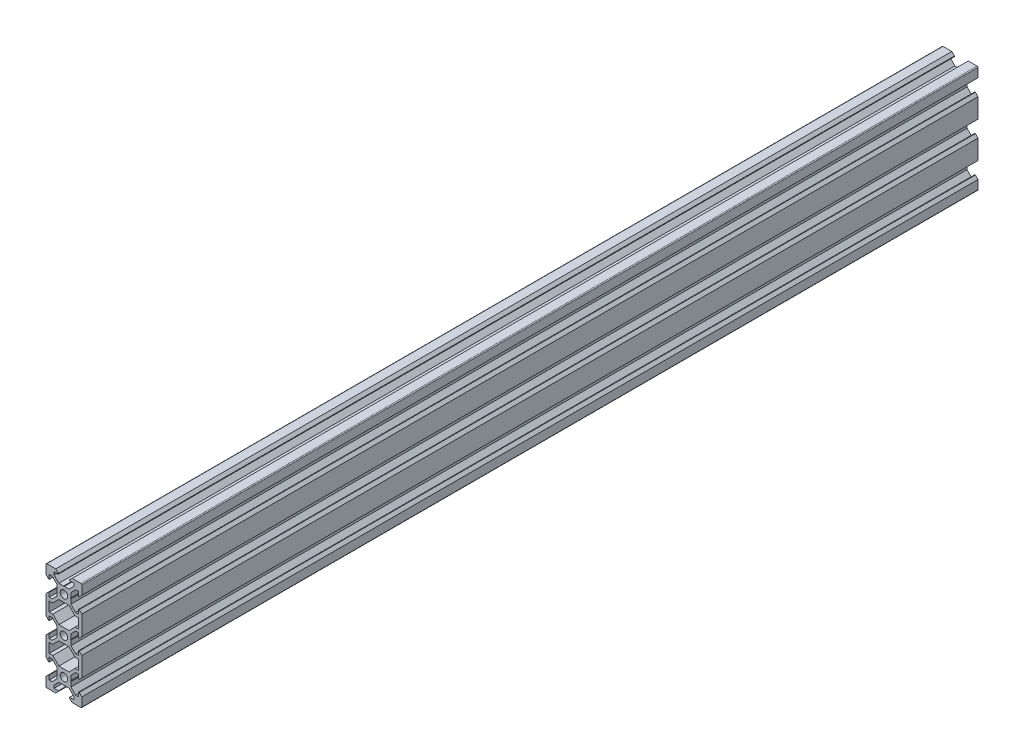
from build123d import *

# Parameters (mm, degrees)
SKETCH1_R           = 2.1
BOSS_EXTRUDE1_DEPTH = 500


with BuildPart() as part:
    # Sketch1 → Boss-Extrude1 (new body)
    with BuildSketch(Plane.XY):
        with BuildLine():
            Line((4.58, -30), (9.5, -30))
            ThreePointArc((9.5, -30), (9.853553391, -29.853553391), (10, -29.5))
            Line((10, -29.5), (10, -24.58))
            Line((10, -24.58), (8.545, -23.125))
            Line((8.545, -23.125), (8.2, -23.125))
            Line((8.2, -23.125), (8.2, -25.5))
            Line((8.2, -25.5), (6.560660172, -25.5))
            Line((6.560660172, -25.5), (3.9, -22.839339828))
            Line((3.9, -22.839339828), (3.9, -20.21))
            Line((3.9, -20.21), (3.69, -20))
            Line((3.69, -20), (3.9, -19.79))
            Line((3.9, -19.79), (3.9, -17.160660172))
            Line((3.9, -17.160660172), (6.560660172, -14.5))
            Line((6.560660172, -14.5), (8.2, -14.5))
            Line((8.2, -14.5), (8.2, -16.875))
            Line((8.2, -16.875), (8.545, -16.875))
            Line((8.545, -16.875), (10, -15.42))
            Line((10, -15.42), (10, -4.58))
            Line((10, -4.58), (8.545, -3.125))
            Line((8.545, -3.125), (8.2, -3.125))
            Line((8.2, -3.125), (8.2, -5.5))
            Line((8.2, -5.5), (6.560660172, -5.5))
            Line((6.560660172, -5.5), (3.9, -2.839339828))
            Line((3.9, -2.839339828), (3.9, -0.21))
            Line((3.9, -0.21), (3.69, 0))
            Line((3.69, 0), (3.9, 0.21))
            Line((3.9, 0.21), (3.9, 2.839339828))
            Line((3.9, 2.839339828), (6.560660172, 5.5))
            Line((6.560660172, 5.5), (8.2, 5.5))
            Line((8.2, 5.5), (8.2, 3.125))
            Line((8.2, 3.125), (8.545, 3.125))
            Line((8.545, 3.125), (10, 4.58))
            Line((10, 4.58), (10, 15.42))
            Line((10, 15.42), (8.545, 16.875))
            Line((8.545, 16.875), (8.2, 16.875))
            Line((8.2, 16.875), (8.2, 14.5))
            Line((8.2, 14.5), (6.560660172, 14.5))
            Line((6.560660172, 14.5), (3.9, 17.160660172))
            Line((3.9, 17.160660172), (3.9, 19.79))
            Line((3.9, 19.79), (3.69, 20))
            Line((3.69, 20), (3.9, 20.21))
            Line((3.9, 20.21), (3.9, 22.839339828))
            Line((3.9, 22.839339828), (6.560660172, 25.5))
            Line((6.560660172, 25.5), (8.2, 25.5))
            Line((8.2, 25.5), (8.2, 23.125))
            Line((8.2, 23.125), (8.545, 23.125))
            Line((8.545, 23.125), (10, 24.58))
            Line((10, 24.58), (10, 29.5))
            ThreePointArc((10, 29.5), (9.853553391, 29.853553391), (9.5, 30))
            Line((9.5, 30), (4.58, 30))
            Line((4.58, 30), (3.125, 28.545))
            Line((3.125, 28.545), (3.125, 28.2))
            Line((3.125, 28.2), (5.5, 28.2))
            Line((5.5, 28.2), (5.5, 26.560660172))
            Line((5.5, 26.560660172), (2.839339828, 23.9))
            Line((2.839339828, 23.9), (0.21, 23.9))
            Line((0.21, 23.9), (0, 23.69))
            Line((0, 23.69), (-0.21, 23.9))
            Line((-0.21, 23.9), (-2.839339828, 23.9))
            Line((-2.839339828, 23.9), (-5.5, 26.560660172))
            Line((-5.5, 26.560660172), (-5.5, 28.2))
            Line((-5.5, 28.2), (-3.125, 28.2))
            Line((-3.125, 28.2), (-3.125, 28.545))
            Line((-3.125, 28.545), (-4.58, 30))
            Line((-4.58, 30), (-9.5, 30))
            ThreePointArc((-9.5, 30), (-9.853553391, 29.853553391), (-10, 29.5))
            Line((-10, 29.5), (-10, 24.58))
            Line((-10, 24.58), (-8.545, 23.125))
            Line((-8.545, 23.125), (-8.2, 23.125))
            Line((-8.2, 23.125), (-8.2, 25.5))
            Line((-8.2, 25.5), (-6.560660172, 25.5))
            Line((-6.560660172, 25.5), (-3.9, 22.839339828))
            Line((-3.9, 22.839339828), (-3.9, 20.21))
            Line((-3.9, 20.21), (-3.69, 20))
            Line((-3.69, 20), (-3.9, 19.79))
            Line((-3.9, 19.79), (-3.9, 17.160660172))
            Line((-3.9, 17.160660172), (-6.560660172, 14.5))
            Line((-6.560660172, 14.5), (-8.2, 14.5))
            Line((-8.2, 14.5), (-8.2, 16.875))
            Line((-8.2, 16.875), (-8.545, 16.875))
            Line((-8.545, 16.875), (-10, 15.42))
            Line((-10, 15.42), (-10, 4.58))
            Line((-10, 4.58), (-8.545, 3.125))
            Line((-8.545, 3.125), (-8.2, 3.125))
            Line((-8.2, 3.125), (-8.2, 5.5))
            Line((-8.2, 5.5), (-6.560660172, 5.5))
            Line((-6.560660172, 5.5), (-3.9, 2.839339828))
            Line((-3.9, 2.839339828), (-3.9, 0.21))
            Line((-3.9, 0.21), (-3.69, 0))
            Line((-3.69, 0), (-3.9, -0.21))
            Line((-3.9, -0.21), (-3.9, -2.839339828))
            Line((-3.9, -2.839339828), (-6.560660172, -5.5))
            Line((-6.560660172, -5.5), (-8.2, -5.5))
            Line((-8.2, -5.5), (-8.2, -3.125))
            Line((-8.2, -3.125), (-8.545, -3.125))
            Line((-8.545, -3.125), (-10, -4.58))
            Line((-10, -4.58), (-10, -15.42))
            Line((-10, -15.42), (-8.545, -16.875))
            Line((-8.545, -16.875), (-8.2, -16.875))
            Line((-8.2, -16.875), (-8.2, -14.5))
            Line((-8.2, -14.5), (-6.560660172, -14.5))
            Line((-6.560660172, -14.5), (-3.9, -17.160660172))
            Line((-3.9, -17.160660172), (-3.9, -19.79))
            Line((-3.9, -19.79), (-3.69, -20))
            Line((-3.69, -20), (-3.9, -20.21))
            Line((-3.9, -20.21), (-3.9, -22.839339828))
            Line((-3.9, -22.839339828), (-6.560660172, -25.5))
            Line((-6.560660172, -25.5), (-8.2, -25.5))
            Line((-8.2, -25.5), (-8.2, -23.125))
            Line((-8.2, -23.125), (-8.545, -23.125))
            Line((-8.545, -23.125), (-10, -24.58))
            Line((-10, -24.58), (-10, -29.5))
            ThreePointArc((-10, -29.5), (-9.853553391, -29.853553391), (-9.5, -30))
            Line((-9.5, -30), (-4.58, -30))
            Line((-4.58, -30), (-3.125, -28.545))
            Line((-3.125, -28.545), (-3.125, -28.2))
            Line((-3.125, -28.2), (-5.5, -28.2))
            Line((-5.5, -28.2), (-5.5, -26.560660172))
            Line((-5.5, -26.560660172), (-2.839339828, -23.9))
            Line((-2.839339828, -23.9), (-0.21, -23.9))
            Line((-0.21, -23.9), (0, -23.69))
            Line((0, -23.69), (0.21, -23.9))
            Line((0.21, -23.9), (2.839339828, -23.9))
            Line((2.839339828, -23.9), (5.5, -26.560660172))
            Line((5.5, -26.560660172), (5.5, -28.2))
            Line((5.5, -28.2), (3.125, -28.2))
            Line((3.125, -28.2), (3.125, -28.545))
            Line((3.125, -28.545), (4.58, -30))
        make_face()
        with Locations((0, -20)):
            Circle(SKETCH1_R, mode=Mode.SUBTRACT)
        Polygon((-6.239339828, -12.7), (-8.2, -12.7), (-8.2, -7.3), (-6.239339828, -7.3), (-2.839339828, -3.9), (2.839339828, -3.9), (6.239339828, -7.3), (8.2, -7.3), (8.2, -12.7), (6.239339828, -12.7), (2.839339828, -16.1), (-2.839339828, -16.1), align=None, mode=Mode.SUBTRACT)
        Polygon((-6.239339828, 7.3), (-8.2, 7.3), (-8.2, 12.7), (-6.239339828, 12.7), (-2.839339828, 16.1), (2.839339828, 16.1), (6.239339828, 12.7), (8.2, 12.7), (8.2, 7.3), (6.239339828, 7.3), (2.839339828, 3.9), (-2.839339828, 3.9), align=None, mode=Mode.SUBTRACT)
        with Locations((0, 20)):
            Circle(SKETCH1_R, mode=Mode.SUBTRACT)
        Circle(SKETCH1_R, mode=Mode.SUBTRACT)
    extrude(amount=BOSS_EXTRUDE1_DEPTH)


solid = part.part
